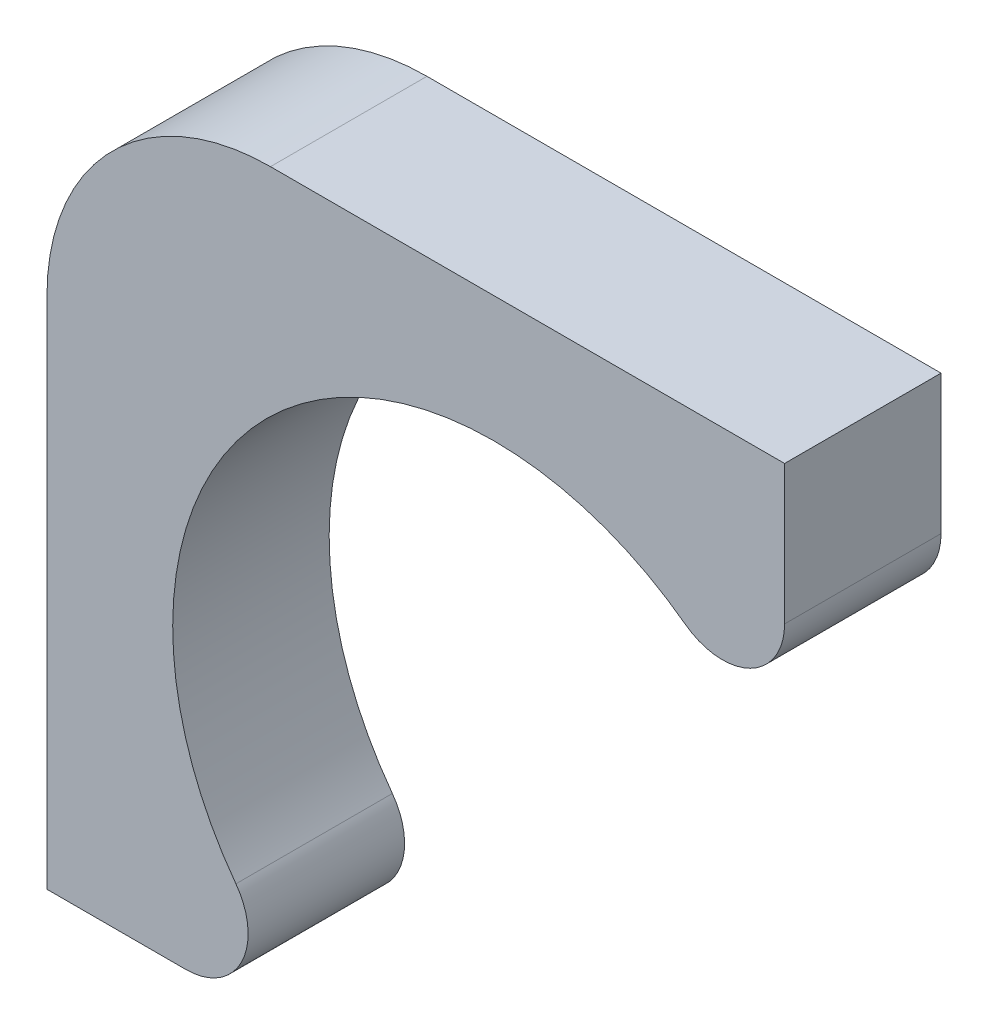
from build123d import *

# Parameters (mm, degrees)
SALIENTE_EXTRUIR1_DEPTH = 1.4


with BuildPart() as part:
    # Croquis1 → Saliente-Extruir1 (new body)
    with BuildSketch(Plane.XY):
        with BuildLine():
            Line((2.6, 4), (-2, 4))
            ThreePointArc((-2, 4), (-3.414213562, 3.414213562), (-4, 2))
            Line((-4, 2), (-4, -2.6))
            Line((-4, -2.6), (-2.756314656, -2.6))
            ThreePointArc((-2.756314656, -2.6), (-2.259416606, -2.293841943), (-2.309436887, -1.712345253))
            ThreePointArc((-2.309436887, -1.712345253), (-2.032931996, 2.032931996), (1.712345253, 2.309436887))
            ThreePointArc((1.712345253, 2.309436887), (2.293841943, 2.259416606), (2.6, 2.756314656))
            Line((2.6, 2.756314656), (2.6, 4))
        make_face()
    extrude(amount=SALIENTE_EXTRUIR1_DEPTH)


solid = part.part
